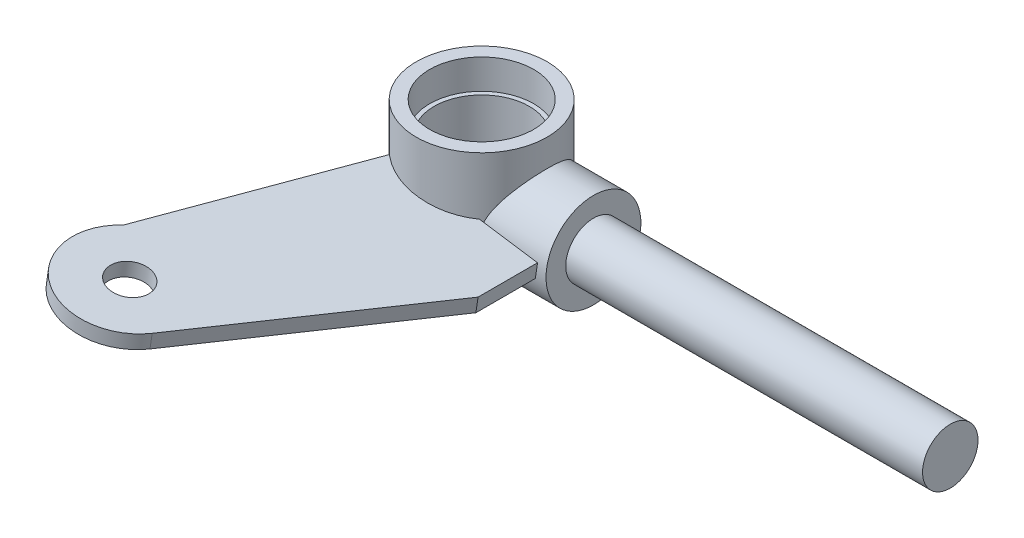
from build123d import *
from build123d.topology import SkipClean

# Parameters (mm, degrees)
BOSS_EXTRUDE2_DEPTH                  = 1.5875
BOSS_EXTRUDE2_DEPTH_BACK             = 1.5875
SKETCH4_R                            = 4.1275
SKETCH5_R                            = 10.130893735
BOSS_EXTRUDE3_DEPTH                  = 9.894952783
BOSS_EXTRUDE3_DIRECTION_2_REACH      = 87.304
BOSS_EXTRUDE3_DIRECTION_2_END_RADIUS = 13.97
SKETCH6_R                            = 5.921066373
BOSS_EXTRUDE4_DEPTH                  = 76.2
CUT_EXTRUDE1_DEPTH                   = 239.285873873
CUT_EXTRUDE1_DEPTH_BACK              = 239.285873873
SKETCH7_W                            = 149.643114042
SKETCH7_H                            = 170.238594894


with BuildPart() as part:
    # Sketch2 → Revolve1 (revolve)
    with BuildSketch(Plane.XY):
        Polygon((13.97, 12.3825), (13.97, -12.3825), (11.1125, -12.3825), (11.1125, -6.0325), (10.16, -6.0325), (10.16, 6.0325), (11.1125, 6.0325), (11.1125, 12.3825), align=None)
    revolve(axis=Axis((0, -12.3825, 0), (0, 1, 0)))


with BuildPart() as body_2:
    # Sketch4 → Boss-Extrude2 (new, two sides: drawn at the far end of the back side and taken through both)
    with BuildSketch(Plane(origin=(0, 0, 0), x_dir=(0, 0, -1), z_dir=(-0.14780941112961093, 0.9890158633619168, 0)).offset(-BOSS_EXTRUDE2_DEPTH_BACK)):
        with BuildLine():
            Line((-54.039928854, -22.925293076), (-10.382944015, -9.346409662))
            ThreePointArc((-10.382944015, -9.346409662), (-13.969031731, 0.164476444), (-10.16, 9.588289733))
            Line((-10.16, 9.588289733), (-10.16, 22.098))
            Line((-10.16, 22.098), (-22.86, 22.098))
            Line((-22.86, 22.098), (-67.999747489, -2.623704278))
            ThreePointArc((-67.999747489, -2.623704278), (-72.254940581, -20.500002013), (-54.039928854, -22.925293076))
        make_face()
        with Locations((-62.0518225, -13.484113782)):
            Circle(SKETCH4_R, mode=Mode.SUBTRACT)
    extrude(amount=BOSS_EXTRUDE2_DEPTH + BOSS_EXTRUDE2_DEPTH_BACK)


with BuildPart() as body_3:
    # Sketch5 → Boss-Extrude3 (new body)
    with BuildSketch(Plane.ZY.offset(13.97)):
        with Locations((0, -3.566641091)):
            Circle(SKETCH5_R)
    extrude(amount=BOSS_EXTRUDE3_DEPTH)

    # Boss-Extrude3 direction 2: up to this cylinder (the profile starts outside it)
    with SkipClean():  # the faces are left unmerged after this step: merging them gives an invalid solid
        boss_extrude3_direction_2_end = Plane(origin=(0, -3.566641, 0), z_dir=(0, -1, 0)) * Cylinder(BOSS_EXTRUDE3_DIRECTION_2_END_RADIUS, 203.548, mode=Mode.PRIVATE)
        # Sketch5 → Boss-Extrude3 direction 2 (add, up to the surface)
        with BuildSketch(Plane.ZY.offset(13.97), mode=Mode.PRIVATE) as boss_extrude3_direction_2_sk1:
            with Locations((0, -3.566641091)):
                Circle(SKETCH5_R)
        boss_extrude3_direction_2_tool1 = extrude(boss_extrude3_direction_2_sk1.sketch, amount=-BOSS_EXTRUDE3_DIRECTION_2_REACH, mode=Mode.PRIVATE) - boss_extrude3_direction_2_end
        add(boss_extrude3_direction_2_tool1.solids().sort_by_distance((-13.97, -3.566641, 0))[0])
        add(boss_extrude3_direction_2_tool1.solids().sort_by_distance((-13.97, -3.566641, 0))[1])

    # Sketch6 → Boss-Extrude4 (add)
    with BuildSketch(Plane.ZY.offset(23.864952783)):
        with Locations((0, -3.566641091)):
            Circle(SKETCH6_R)
    extrude(amount=BOSS_EXTRUDE4_DEPTH)


with BuildPart() as body_4:
    # Mirror1: mirrored copy
    add(body_2.part.mirror(Plane(origin=(-100.064952783, -3.566641091, 0), x_dir=(0, 0, 1), z_dir=(-1, 0, 0))))


with BuildPart() as body_5:
    # Mirror1 2: mirrored copy
    add(body_3.part.mirror(Plane(origin=(-100.064952783, -3.566641091, 0), x_dir=(0, 0, 1), z_dir=(-1, 0, 0))))


with BuildPart() as body_6:
    # Mirror1 3: mirrored copy
    add(part.part.mirror(Plane(origin=(-100.064952783, -3.566641091, 0), x_dir=(0, 0, 1), z_dir=(-1, 0, 0))))


with BuildPart() as cut_extrude1_tool:
    # Sketch7 → Cut-Extrude1 (new, two sides: drawn at the far end of the back side and taken through both)
    with BuildSketch(Plane(origin=(0, 0, 0), x_dir=(1, 0, 0), z_dir=(0, 1, 0)).offset(-CUT_EXTRUDE1_DEPTH_BACK)):
        with Locations((-25.243395762, -25.539520043)):
            Rectangle(SKETCH7_W, SKETCH7_H)
    extrude(amount=CUT_EXTRUDE1_DEPTH + CUT_EXTRUDE1_DEPTH_BACK)


with BuildPart() as part_1:
    add(part.part)

    # Cut-Extrude1: cut by cut_extrude1_tool
    add(cut_extrude1_tool.part, mode=Mode.SUBTRACT)


with BuildPart() as body_2_1:
    add(body_2.part)

    # Cut-Extrude1: cut by cut_extrude1_tool
    add(cut_extrude1_tool.part, mode=Mode.SUBTRACT)


with BuildPart() as body_3_1:
    add(body_3.part)

    # Cut-Extrude1: cut by cut_extrude1_tool
    add(cut_extrude1_tool.part, mode=Mode.SUBTRACT)


solid = Compound([body_4.part, body_5.part, body_6.part])
